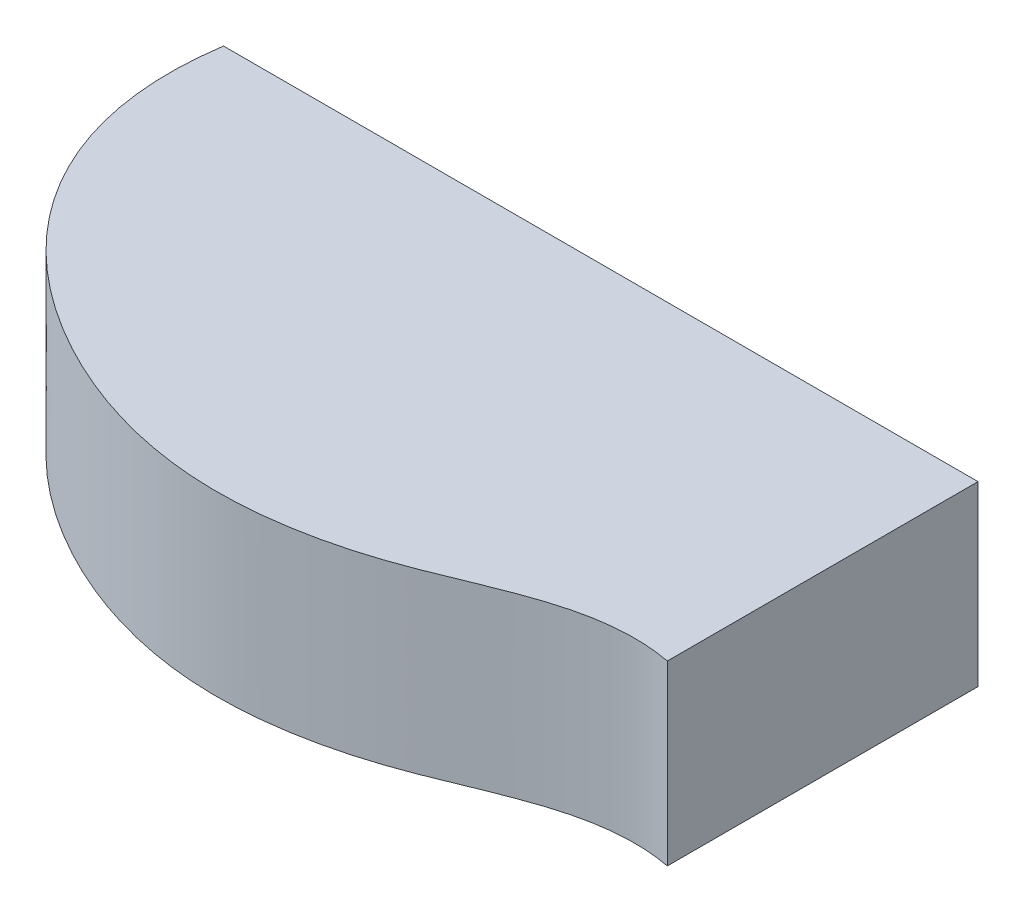
from build123d import *

# Parameters (mm, degrees)
BOSS_EXTRUDE1_DEPTH = 3.175
BOSS_EXTRUDE2_DEPTH = 25.4
SKETCH4_R           = 3.175
BOSS_EXTRUDE3_DEPTH = 23.876
SKETCH5_W           = 65
SKETCH5_H           = 35.5
BOSS_EXTRUDE4_DEPTH = 21.14


with BuildPart() as part:
    # Sketch1 → Boss-Extrude1 (new body)
    with BuildSketch(Plane(origin=(0, 0, 0), x_dir=(1, 0, 0), z_dir=(0, 1, 0))):
        with BuildLine():
            Line((0, 0), (-107.95, 0))
            add(Edge.make_bspline(
                [(-107.95, 0), (-111.264371581, -22.223355165), (-93.128309356, -45.976040953), (-57.609622492, -57.69778745), (-28.725306534, -52.845882242), (-11.819511833, -42.209688066), (0, -44.45)],
                knots=[0, 0, 0, 0, 0.396763779, 0.585186104, 0.766934878, 1, 1, 1, 1], degree=3))
            Line((0, -44.45), (0, 0))
        make_face()
    extrude(amount=BOSS_EXTRUDE1_DEPTH)

    # Sketch3 → Boss-Extrude2 (add)
    with BuildSketch(Plane(origin=(0, 3.175, 0), x_dir=(1, 0, 0), z_dir=(0, 1, 0))):
        with BuildLine():
            Line((-107.95, 0), (0, 0))
            Line((0, 0), (0, -44.45))
            add(Edge.make_bspline(
                [(-107.95, 0), (-111.264371581, -22.223355165), (-93.128309356, -45.976040953), (-57.609622492, -57.69778745), (-28.725306534, -52.845882242), (-11.819511833, -42.209688066), (0, -44.45)],
                knots=[0, 0, 0, 0, 0.396763779, 0.585186104, 0.766934878, 1, 1, 1, 1], degree=3))
        make_face()
        with BuildLine():
            Line((-3.175, -3.175), (-3.175, -40.851813342))
            add(Edge.make_bspline(
                [(-3.175, -40.851813342), (-3.981241555, -40.799236826), (-5.613173677, -40.758071121), (-8.755907484, -40.91833994), (-12.544966377, -41.515078302), (-16.858992044, -42.692888995), (-22.365050245, -44.656719953), (-27.607498849, -46.904281185), (-32.742546929, -48.882210607), (-37.923615998, -50.544033975), (-44.576686254, -52.030970183), (-52.639871626, -52.729404253), (-60.625408491, -52.20082035), (-68.513307445, -50.421711202), (-76.136701649, -47.534738566), (-83.353587797, -43.660935754), (-89.925307122, -38.936837432), (-95.60948708, -33.390844892), (-100.196904726, -27.060690394), (-102.946013069, -21.145493232), (-104.40794392, -16.016511773), (-105.110198278, -11.965850914), (-105.342998437, -8.407656976), (-105.303439388, -5.46128014), (-105.203482374, -3.930833291), (-105.134910032, -3.175)],
                knots=[0.017398094, 0.017398094, 0.017398094, 0.017398094, 0.032397512, 0.047396929, 0.077395765, 0.107394601, 0.137393436, 0.197391108, 0.227389943, 0.257388779, 0.31738645, 0.377384122, 0.437381793, 0.497379464, 0.557377136, 0.617374807, 0.677372478, 0.73737015, 0.797367821, 0.857365492, 0.887364328, 0.917363164, 0.947361999, 0.962361417, 0.977360835, 0.977360835, 0.977360835, 0.977360835], degree=3))
            Line((-105.134910032, -3.175), (-3.175, -3.175))
        make_face(mode=Mode.SUBTRACT)
    extrude(amount=-BOSS_EXTRUDE2_DEPTH)

    # Sketch4 → Boss-Extrude3 (add)
    with BuildSketch(Plane(origin=(0, -22.225, 0), x_dir=(-1, 0, 0), z_dir=(0, -1, 0))):
        with Locations((105.134910032, -3.175)):
            Circle(SKETCH4_R)
        with Locations((3.175, -3.175)):
            Circle(SKETCH4_R)
        with Locations((3.175, -40.851813342)):
            Circle(SKETCH4_R)
    extrude(amount=-BOSS_EXTRUDE3_DEPTH)

    # Sketch5 → Boss-Extrude4 (add)
    with BuildSketch(Plane.XZ):
        with Locations((-38.85, 20.925)):
            Rectangle(SKETCH5_W, SKETCH5_H)
    extrude(amount=BOSS_EXTRUDE4_DEPTH)


solid = part.part
